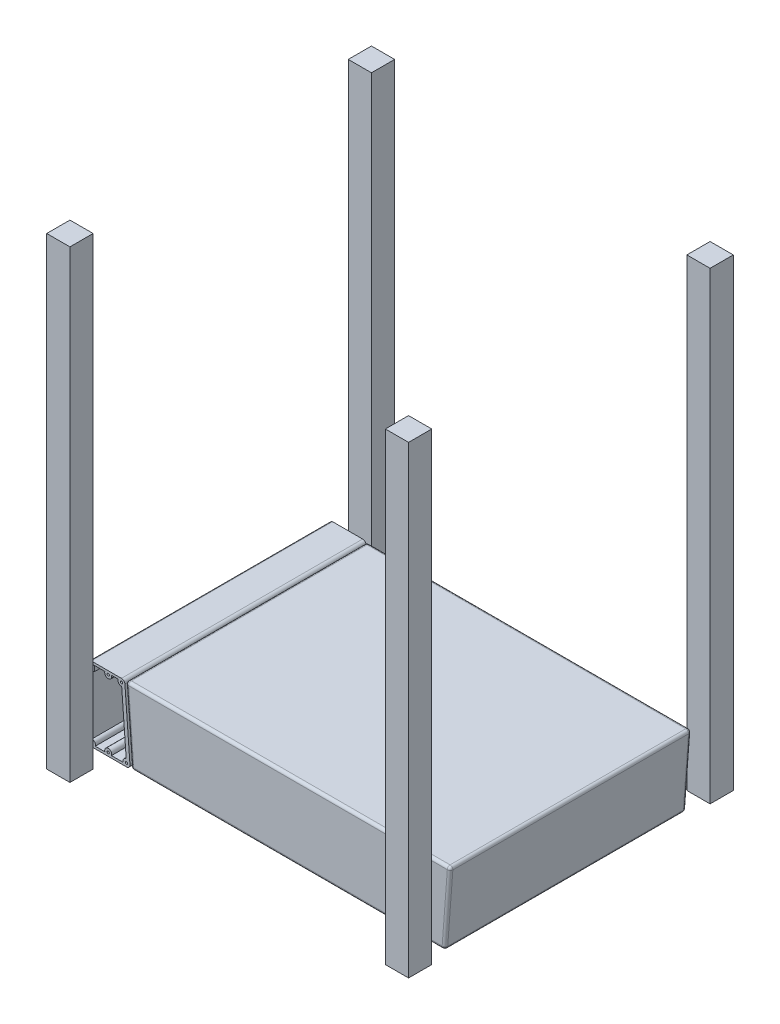
from build123d import *

# Parameters (mm, degrees)
SKETCH_1_W          = 350
SKETCH_1_H          = 260
EXTRUDE_5_DEPTH     = 80
CUT_EXTRUDE_1_DEPTH = 262
CUT_EXTRUDE_2_DEPTH = 262
FILLET_2_R          = 3
SKETCH_1_9_W        = 25
SKETCH_1_9_H        = 25
EXTRUDE_6_DEPTH     = 500
EXTRUDE_6_2_DEPTH   = 500
EXTRUDE_6_3_DEPTH   = 500
EXTRUDE_6_4_DEPTH   = 500
SKETCH_32_R         = 1.25
EXTRUDE_17_DEPTH    = 260
EXTRUDE_18_DEPTH    = 260


with BuildPart() as part:
    # 스케치1 → 보스-돌출5 (new body)
    with BuildSketch(Plane(origin=(0, 0, 0), x_dir=(1, 0, 0), z_dir=(0, 1, 0))):
        with Locations((20, 0)):
            Rectangle(SKETCH_1_W, SKETCH_1_H)
    extrude(amount=EXTRUDE_5_DEPTH)

    # 스케치5 → 컷-돌출1 (cut)
    with BuildSketch(Plane.XY.offset(130)):
        Polygon((-155, 80), (-149, 0), (-155, 0), align=None)
    extrude(amount=-CUT_EXTRUDE_1_DEPTH, mode=Mode.SUBTRACT)

    # 스케치6 → 컷-돌출2 (cut)
    with BuildSketch(Plane.XY.offset(130)):
        Polygon((195, 0), (189, 0), (195, 80), align=None)
    extrude(amount=-CUT_EXTRUDE_2_DEPTH, mode=Mode.SUBTRACT)

    # 필렛2
    fillet_2_edges = [part.edges().sort_by_distance(p)[0] for p in [
        (20, 80, 130),
        (195, 80, 0),
        (-149, 0, 0),
        (-152, 40, -130),
        (-152, 40, 130),
        (20, 0, 130),
        (20, 0, -130),
        (189, 0, 0),
        (192, 40, -130),
        (192, 40, 130),
        (20, 80, -130),
        (-155, 80, 0),
    ]]
    fillet(fillet_2_edges, radius=FILLET_2_R)


with BuildPart() as body_2:
    # 스케치1<9> → 보스-돌출6 (new body)
    with BuildSketch(Plane(origin=(0, 0, 0), x_dir=(1, 0, 0), z_dir=(0, 1, 0))):
        with Locations((-182.5, -162.5)):
            Rectangle(SKETCH_1_9_W, SKETCH_1_9_H)
    extrude(amount=EXTRUDE_6_DEPTH)


with BuildPart() as body_3:
    # 스케치1<9> → Extrude 6 2 (new body)
    with BuildSketch(Plane(origin=(0, 0, 0), x_dir=(1, 0, 0), z_dir=(0, 1, 0))):
        with Locations((182.5, -162.5)):
            Rectangle(SKETCH_1_9_W, SKETCH_1_9_H)
    extrude(amount=EXTRUDE_6_2_DEPTH)


with BuildPart() as body_4:
    # 스케치1<9> → Extrude 6 3 (new body)
    with BuildSketch(Plane(origin=(0, 0, 0), x_dir=(1, 0, 0), z_dir=(0, 1, 0))):
        with Locations((182.5, 162.5)):
            Rectangle(SKETCH_1_9_W, SKETCH_1_9_H)
    extrude(amount=EXTRUDE_6_3_DEPTH)


with BuildPart() as body_5:
    # 스케치1<9> → Extrude 6 4 (new body)
    with BuildSketch(Plane(origin=(0, 0, 0), x_dir=(1, 0, 0), z_dir=(0, 1, 0))):
        with Locations((-182.5, 162.5)):
            Rectangle(SKETCH_1_9_W, SKETCH_1_9_H)
    extrude(amount=EXTRUDE_6_4_DEPTH)


with BuildPart() as body_6:
    # 스케치32 → 보스-돌출17 (new body)
    with BuildSketch(Plane.XY.offset(130)):
        with BuildLine():
            ThreePointArc((-195, 3.75), (-193.901650429, 1.098349571), (-191.25, 0))
            Line((-191.25, 0), (-154.044590641, 0))
            ThreePointArc((-154.044590641, 0), (-151.295569575, 1.199434734), (-150.305093229, 4.030462306))
            Line((-150.305093229, 4.030462306), (-155.742593229, 76.530462306))
            Line((-155.742593229, 76.530462306), (-158.235591504, 76.343487435))
            ThreePointArc((-158.235591504, 76.343487435), (-160.332279063, 75.333659645), (-159.482090641, 77.5))
            Line((-159.482090641, 77.5), (-163.017624547, 77.5))
            ThreePointArc((-163.017624547, 77.5), (-162.460788995, 73.97187443), (-159.201628335, 72.510502588))
            Line((-159.201628335, 72.510502588), (-154.325052947, 7.489497412))
            ThreePointArc((-154.325052947, 7.489497412), (-157.185327478, 5.798968551), (-157.580124547, 2.5))
            Line((-157.580124547, 2.5), (-170.214466094, 2.5))
            ThreePointArc((-170.214466094, 2.5), (-173.75, 7.5), (-177.285533906, 2.5))
            Line((-177.285533906, 2.5), (-187.714466094, 2.5))
            ThreePointArc((-187.714466094, 2.5), (-188.188137822, 5.915063509), (-191.25, 7.5))
            Line((-191.25, 7.5), (-191.25, 71.5))
            Line((-191.25, 71.5), (-188.75, 71.5))
            Line((-188.75, 71.5), (-188.75, 77))
            Line((-188.75, 77), (-191, 77))
            Line((-191, 77), (-191, 74.5))
            Line((-191, 74.5), (-195, 74.5))
            Line((-195, 74.5), (-195, 3.75))
        make_face()
        with Locations((-154.044590641, 3.75)):
            Circle(SKETCH_32_R, mode=Mode.SUBTRACT)
        with Locations((-191.25, 3.75)):
            Circle(SKETCH_32_R, mode=Mode.SUBTRACT)
        with Locations((-173.75, 3.75)):
            Circle(SKETCH_32_R, mode=Mode.SUBTRACT)
    extrude(amount=-EXTRUDE_17_DEPTH)

    # 스케치32<7> → 보스-돌출18 (add)
    with BuildSketch(Plane.XY.offset(130)):
        with BuildLine():
            Line((-158.235591504, 76.343487435), (-155.742593229, 76.530462306))
            ThreePointArc((-155.742593229, 76.530462306), (-156.931525375, 78.999021066), (-159.482090641, 80))
            Line((-159.482090641, 80), (-159.482090641, 77.5))
            ThreePointArc((-159.482090641, 77.5), (-158.631902219, 77.166340355), (-158.235591504, 76.343487435))
        make_face()
        with BuildLine():
            Line((-159.482090641, 77.5), (-159.482090641, 80))
            ThreePointArc((-159.482090641, 80), (-161.64715415, 79.311862178), (-163.017624547, 77.5))
            Line((-163.017624547, 77.5), (-159.482090641, 77.5))
        make_face()
        with BuildLine():
            Line((-159.482090641, 80), (-173.75, 80))
            ThreePointArc((-173.75, 80), (-171.584936491, 79.311862178), (-170.214466094, 77.5))
            Line((-170.214466094, 77.5), (-163.017624547, 77.5))
            ThreePointArc((-163.017624547, 77.5), (-161.64715415, 79.311862178), (-159.482090641, 80))
        make_face()
        with BuildLine():
            ThreePointArc((-170.214466094, 77.5), (-171.584936491, 79.311862178), (-173.75, 80))
            ThreePointArc((-173.75, 80), (-175.915063509, 79.311862178), (-177.285533906, 77.5))
            Line((-177.285533906, 77.5), (-173.75, 77.5))
            Line((-173.75, 77.5), (-170.214466094, 77.5))
        make_face()
        with BuildLine():
            ThreePointArc((-170, 76.25), (-170.054005401, 76.88413242), (-170.214466094, 77.5))
            Line((-170.214466094, 77.5), (-173.75, 77.5))
            Line((-173.75, 77.5), (-177.285533906, 77.5))
            ThreePointArc((-177.285533906, 77.5), (-174.38413242, 72.554005401), (-170, 76.25))
        make_face()
        with BuildLine():
            ThreePointArc((-172.5, 76.25), (-174.633883476, 75.366116524), (-173.75, 77.5))
            ThreePointArc((-173.75, 77.5), (-172.866116524, 77.133883476), (-172.5, 76.25))
        make_face(mode=Mode.SUBTRACT)
        with BuildLine():
            Line((-191.530628811, 80), (-192, 80))
            ThreePointArc((-192, 80), (-193.414213562, 79.414213562), (-194, 78))
            Line((-194, 78), (-194, 77))
            Line((-194, 77), (-194, 75))
            Line((-194, 75), (-191.5, 75))
            Line((-191.5, 75), (-191.5, 77.5))
            Line((-191.5, 77.5), (-190.549934157, 77.5))
            Line((-190.549934157, 77.5), (-177.285533906, 77.5))
            ThreePointArc((-177.285533906, 77.5), (-175.915063509, 79.311862178), (-173.75, 80))
            Line((-173.75, 80), (-191.25, 80))
            Line((-191.25, 80), (-191.530628811, 80))
        make_face()
    extrude(amount=-EXTRUDE_18_DEPTH)


solid = Compound([part.part, body_2.part, body_3.part, body_4.part, body_5.part, body_6.part])
